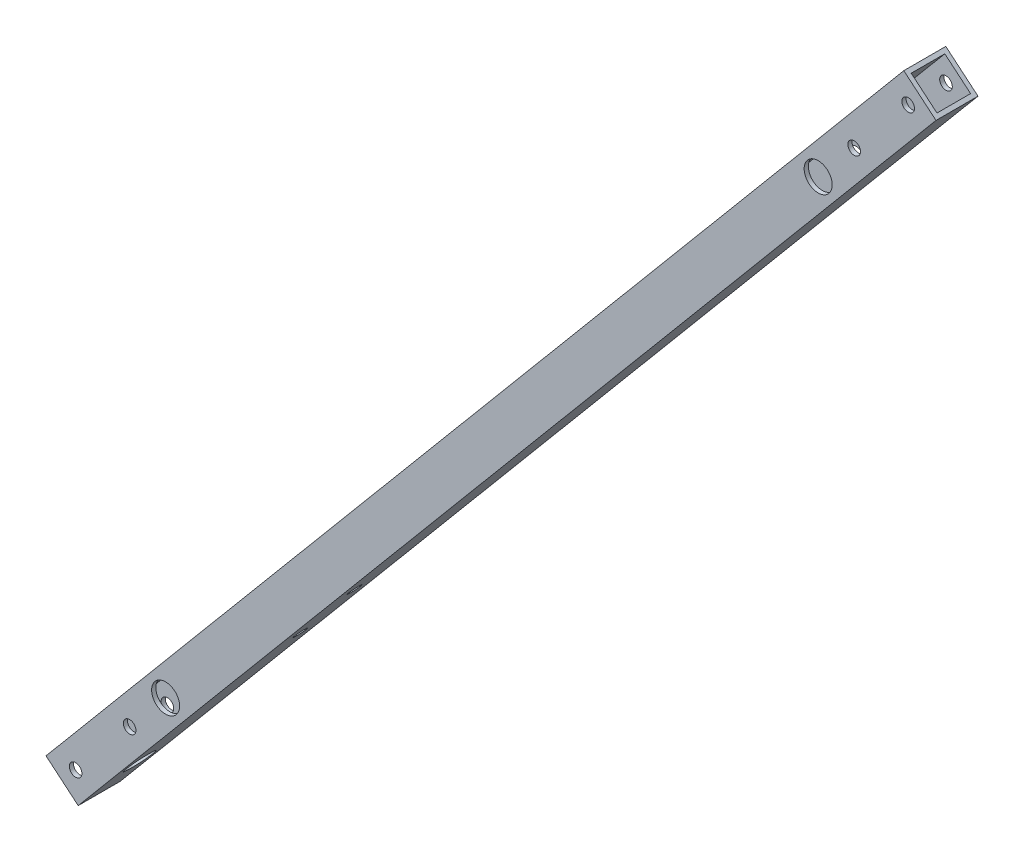
from build123d import *

# Parameters (mm, degrees)
EXTRUDE_1_DEPTH             = 15
SHELL_1_T                   = -1.5
SKETCH_3_R                  = 2.25
SKETCH_3_R_2                = 2.7
CUT_EXTRUDE_1_DEPTH         = 25
SKETCH_5_R                  = 2.25
SKETCH_5_R_2                = 2.7
CUT_EXTRUDE_3_DEPTH         = 20
SKETCH_7_W                  = 15
SKETCH_7_H                  = 15
SKETCH_7_W_2                = 12
SKETCH_7_H_2                = 12
CUT_EXTRUDE_4_DEPTH         = 1
HOLE_WIZARD_10_0_10_1_D     = 10
HOLE_WIZARD_10_0_10_1_DEPTH = 1.5
HOLE_WIZARD_10_0_10_2_D     = 10
HOLE_WIZARD_10_0_10_2_DEPTH = 1.5


with BuildPart() as part:
    # ｽｹｯﾁ1 → ﾎﾞｽ - 押し出し1 (new body)
    with BuildSketch(Plane.XY):
        Polygon((306.8847856, 365.731045751), (0, 0), (-11.490666647, 9.641814145), (295.394118953, 375.372859896), align=None)
    extrude(amount=EXTRUDE_1_DEPTH)

    # ｼｪﾙ1
    shell_1_openings = [part.faces().sort_by_distance(p)[0] for p in [
        (301.139452276, 370.551952824, 7.5),
        (-5.745333323, 4.820907073, 7.5),
    ]]
    offset(amount=SHELL_1_T, openings=shell_1_openings, kind=Kind.INTERSECTION)

    # ｽｹｯﾁ3 → ｶｯﾄ - 押し出し1 (cut)
    with BuildSketch(Plane.XY.offset(15)):
        with Locations((-0.924426251, 10.566240396)):
            Circle(SKETCH_3_R)
        with Locations((18.35920204, 33.54757369)):
            Circle(SKETCH_3_R)
        with Locations((277.034916913, 341.825286207)):
            Circle(SKETCH_3_R)
        with Locations((296.318545204, 364.8066195)):
            Circle(SKETCH_3_R)
        with Locations((31.214954234, 48.868462552)):
            Circle(SKETCH_3_R_2)
        with Locations((264.179164719, 326.504397344)):
            Circle(SKETCH_3_R_2)
    extrude(amount=-CUT_EXTRUDE_1_DEPTH, mode=Mode.SUBTRACT)

    # ｽｹｯﾁ5 → ｶｯﾄ - 押し出し3 (cut)
    with BuildSketch(Plane(origin=(-11.490666647, 9.641814145, 0), x_dir=(0, 0, 1), z_dir=(-0.766044443, 0.64278761, 0))):
        with Locations((7.5, 141.822406051)):
            Circle(SKETCH_5_R)
        with Locations((7.5, 111.822406051)):
            Circle(SKETCH_5_R)
        with Locations((7.5, 22.5)):
            Circle(SKETCH_5_R_2)
    extrude(amount=-CUT_EXTRUDE_3_DEPTH, mode=Mode.SUBTRACT)

    # ｽｹｯﾁ7 → ｶｯﾄ - 押し出し4 (cut)
    with BuildSketch(Plane(origin=(306.8847856, 365.731045751, 0), x_dir=(0.766044443, -0.64278761, 0), z_dir=(0.64278761, 0.766044443, 0))):
        with Locations((-7.5, -7.5)):
            Rectangle(SKETCH_7_W, SKETCH_7_H)
        with Locations((-7.5, -7.5)):
            Rectangle(SKETCH_7_W_2, SKETCH_7_H_2, mode=Mode.SUBTRACT)
    extrude(amount=-CUT_EXTRUDE_4_DEPTH, mode=Mode.SUBTRACT)

    # Ø10.0 (10) 直径の穴1
    with Locations(Plane(origin=(0, 0, 0), x_dir=(0, 0, -1), z_dir=(0.766044443, -0.64278761, 0))):
        with Locations((-7.5, 22.5)):
            Hole(HOLE_WIZARD_10_0_10_1_D / 2, depth=HOLE_WIZARD_10_0_10_1_DEPTH)

    # Ø10.0 (10) 直径の穴2
    with Locations(Plane.XY.offset(15)):
        with Locations((31.214954234, 48.868462552), (264.179164719, 326.504397344)):
            Hole(HOLE_WIZARD_10_0_10_2_D / 2, depth=HOLE_WIZARD_10_0_10_2_DEPTH)


solid = part.part
